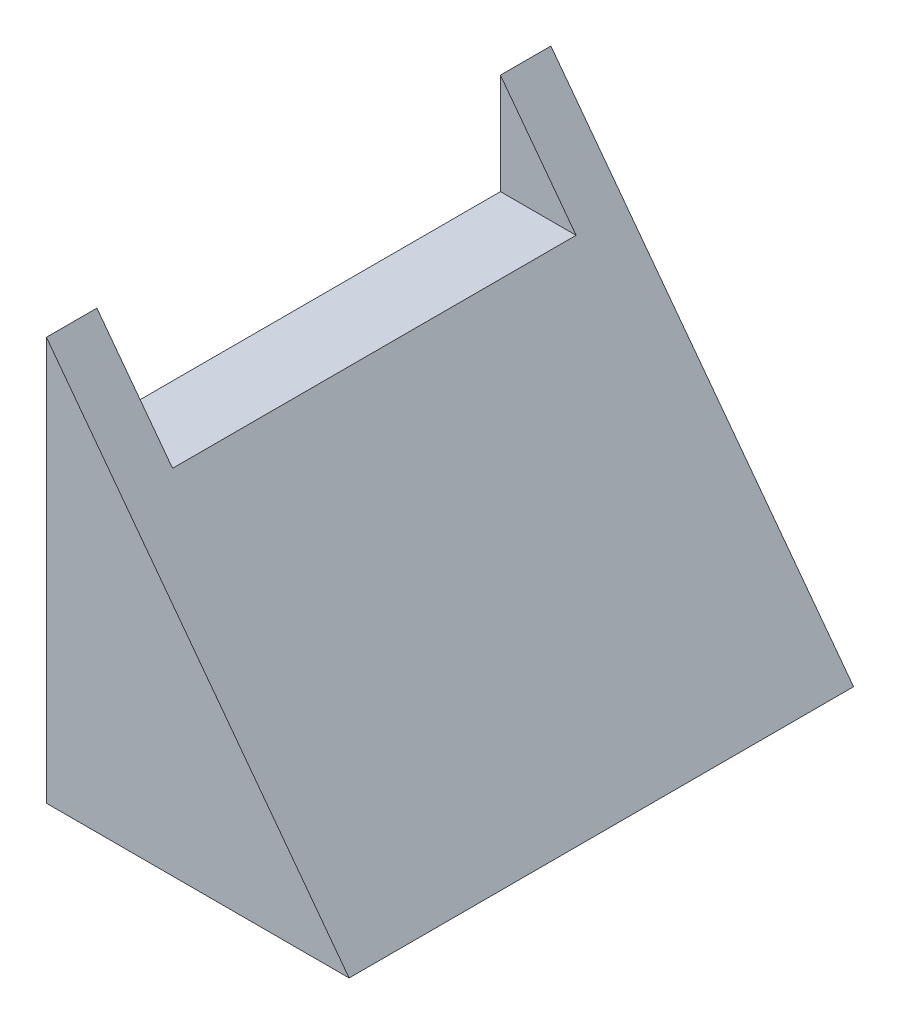
from build123d import *

# Parameters (mm, degrees)
BOSS_EXTRUDE1_DEPTH = 63.5
SKETCH2_W           = 50.8
SKETCH2_H           = 12.7
CUT_EXTRUDE2_DEPTH  = 39.1


with BuildPart() as part:
    # Sketch1 → Boss-Extrude1 (new body)
    with BuildSketch(Plane.XY):
        Polygon((19.05, 0), (-19.05, 0), (-19.05, 50.8), align=None)
    extrude(amount=BOSS_EXTRUDE1_DEPTH)

    # Sketch2 → Cut-Extrude2 (cut, through all)
    with BuildSketch(Plane.ZY.offset(19.05)):
        with Locations((31.75, 44.45)):
            Rectangle(SKETCH2_W, SKETCH2_H)
    extrude(amount=-CUT_EXTRUDE2_DEPTH, mode=Mode.SUBTRACT)


solid = part.part
